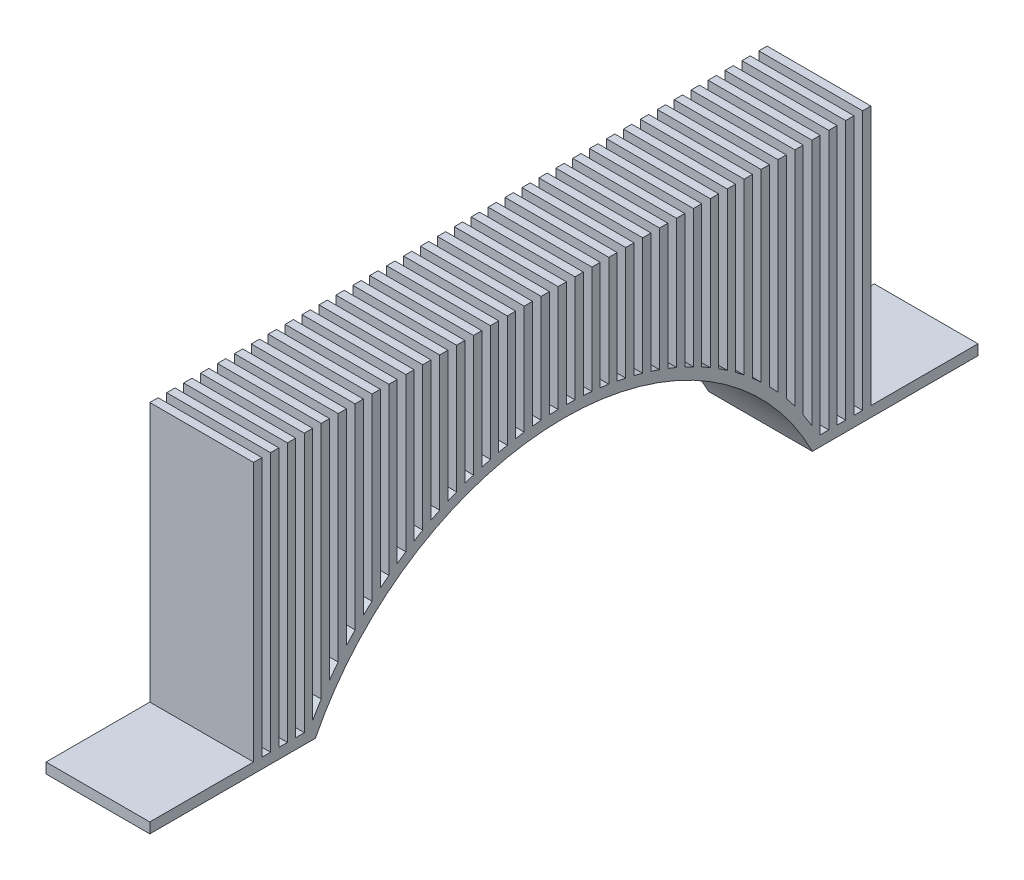
from build123d import *

# Parameters (mm, degrees)
SKETCH1_W           = 0.8
SKETCH1_H           = 25
BOSS_EXTRUDE1_DEPTH = 10


with BuildPart() as part:
    # Sketch1 → Boss-Extrude1 (new body)
    with BuildSketch(Plane(origin=(0, 0, 0), x_dir=(0, 0, -1), z_dir=(1, 0, 0))):
        with Locations((-26.24, 14.5)):
            Rectangle(SKETCH1_W, SKETCH1_H)
        with BuildLine():
            Line((-21.75, 27), (-21.75, 6.264083863))
            ThreePointArc((-21.75, 6.264083863), (-21.355393676, 6.748515695), (-20.95, 7.223956879))
            Line((-20.95, 7.223956879), (-20.95, 27))
            Line((-20.95, 27), (-21.75, 27))
        make_face()
        with BuildLine():
            Line((-20.12, 27), (-20.12, 8.133993328))
            ThreePointArc((-20.12, 8.133993328), (-19.724111766, 8.540799244), (-19.32, 8.939437211))
            Line((-19.32, 8.939437211), (-19.32, 27))
            Line((-19.32, 27), (-20.12, 27))
        make_face()
        with BuildLine():
            ThreePointArc((-18.49, 9.709573695), (-18.093249547, 10.056262597), (-17.69, 10.39537013))
            Line((-17.69, 10.39537013), (-17.69, 27))
            Line((-17.69, 27), (-18.49, 27))
            Line((-18.49, 27), (-18.49, 9.709573695))
        make_face()
        with BuildLine():
            Line((-16.86, 27), (-16.86, 11.053854867))
            ThreePointArc((-16.86, 11.053854867), (-16.462624666, 11.351383643), (-16.06, 11.641769433))
            Line((-16.06, 11.641769433), (-16.06, 27))
            Line((-16.06, 27), (-16.86, 27))
        make_face()
        with BuildLine():
            Line((-15.23, 27), (-15.23, 12.206979598))
            ThreePointArc((-15.23, 12.206979598), (-14.832146447, 12.462707879), (-14.43, 12.711630836))
            Line((-14.43, 12.711630836), (-14.43, 27))
            Line((-14.43, 27), (-15.23, 27))
        make_face()
        with Locations((-29.5, 14.5)):
            Rectangle(SKETCH1_W, SKETCH1_H)
        with BuildLine():
            ThreePointArc((-24.546639281, 2), (-24.38025515, 2.30826182), (-24.21, 2.614402658))
            Line((-24.21, 2.614402658), (-24.21, 27))
            Line((-24.21, 27), (-25.01, 27))
            Line((-25.01, 27), (-25.01, 2))
            Line((-25.01, 2), (-24.546639281, 2))
        make_face()
        with BuildLine():
            Line((-23.38, 27), (-23.38, 3.990465418))
            ThreePointArc((-23.38, 3.990465418), (-22.987525369, 4.583735235), (-22.58, 5.166769099))
            Line((-22.58, 5.166769099), (-22.58, 27))
            Line((-22.58, 27), (-23.38, 27))
        make_face()
        with BuildLine():
            Line((-13.6, 27), (-13.6, 13.196236821))
            ThreePointArc((-13.6, 13.196236821), (-13.201764607, 13.415351239), (-12.8, 13.627925359))
            Line((-12.8, 13.627925359), (-12.8, 27))
            Line((-12.8, 27), (-13.6, 27))
        make_face()
        with BuildLine():
            Line((-11.97, 27), (-11.97, 14.041016321))
            ThreePointArc((-11.97, 14.041016321), (-11.571448918, 14.227293564), (-11.17, 14.40724062))
            Line((-11.17, 14.40724062), (-11.17, 27))
            Line((-11.17, 27), (-11.97, 27))
        make_face()
        with BuildLine():
            Line((-10.34, 27), (-10.34, 14.755511039))
            ThreePointArc((-10.34, 14.755511039), (-9.941180009, 14.911759186), (-9.54, 15.061844056))
            Line((-9.54, 15.061844056), (-9.54, 27))
            Line((-9.54, 27), (-10.34, 27))
        make_face()
        with BuildLine():
            Line((-8.71, 27), (-8.71, 15.350301135))
            ThreePointArc((-8.71, 15.350301135), (-8.31094479, 15.478629755), (-7.91, 15.600926813))
            Line((-7.91, 15.600926813), (-7.91, 27))
            Line((-7.91, 27), (-8.71, 27))
        make_face()
        with BuildLine():
            Line((-7.08, 27), (-7.08, 15.833333127))
            ThreePointArc((-7.08, 15.833333127), (-6.680733977, 15.935325522), (-6.28, 16.031388443))
            Line((-6.28, 16.031388443), (-6.28, 27))
            Line((-6.28, 27), (-7.08, 27))
        make_face()
        with BuildLine():
            Line((-5.45, 27), (-5.45, 16.210548417))
            ThreePointArc((-5.45, 16.210548417), (-5.050540677, 16.287374396), (-4.65, 16.358347269))
            Line((-4.65, 16.358347269), (-4.65, 27))
            Line((-4.65, 27), (-5.45, 27))
        make_face()
        with BuildLine():
            Line((-3.82, 27), (-3.82, 16.486296047))
            ThreePointArc((-3.82, 16.486296047), (-3.420359517, 16.538786504), (-3.02, 16.585477199))
            Line((-3.02, 16.585477199), (-3.02, 27))
            Line((-3.02, 27), (-3.82, 27))
        make_face()
        with BuildLine():
            Line((-2.19, 27), (-2.19, 16.663604962))
            ThreePointArc((-2.19, 16.663604962), (-1.790186091, 16.692300441), (-1.39, 16.715228254))
            Line((-1.39, 16.715228254), (-1.39, 27))
            Line((-1.39, 27), (-2.19, 27))
        make_face()
        with BuildLine():
            ThreePointArc((-0.56, 16.74435914), (-0.160016565, 16.749539469), (0.24, 16.748964009))
            Line((0.24, 16.748964009), (0.24, 27))
            Line((0.24, 27), (-0.56, 27))
            Line((-0.56, 27), (-0.56, 16.74435914))
        make_face()
        with BuildLine():
            ThreePointArc((1.07, 16.729400641), (1.470152617, 16.711099605), (1.87, 16.687034809))
            Line((1.87, 16.687034809), (1.87, 27))
            Line((1.87, 27), (1.07, 27))
            Line((1.07, 27), (1.07, 16.729400641))
        make_face()
        with BuildLine():
            ThreePointArc((2.7, 16.618574231), (3.100324987, 16.576581131), (3.5, 16.528796203))
            Line((3.5, 16.528796203), (3.5, 27))
            Line((3.5, 27), (2.7, 27))
            Line((2.7, 27), (2.7, 16.618574231))
        make_face()
        with BuildLine():
            ThreePointArc((4.33, 16.410719219), (4.730504303, 16.34456751), (5.13, 16.272574915))
            Line((5.13, 16.272574915), (5.13, 27))
            Line((5.13, 27), (4.33, 27))
            Line((4.33, 27), (4.33, 16.410719219))
        make_face()
        with BuildLine():
            ThreePointArc((5.96, 16.103607495), (6.360694834, 16.012549053), (6.76, 15.915578058))
            Line((6.76, 15.915578058), (6.76, 27))
            Line((6.76, 27), (5.96, 27))
            Line((5.96, 27), (5.96, 16.103607495))
        make_face()
        with BuildLine():
            ThreePointArc((7.59, 15.693819847), (7.990901723, 15.576781436), (8.39, 15.453733699))
            Line((8.39, 15.453733699), (8.39, 27))
            Line((8.39, 27), (7.59, 27))
            Line((7.59, 27), (7.59, 15.693819847))
        make_face()
        with BuildLine():
            ThreePointArc((9.22, 15.176543806), (9.621131509, 15.032059514), (10.02, 14.881440377))
            Line((10.02, 14.881440377), (10.02, 27))
            Line((10.02, 27), (9.22, 27))
            Line((9.22, 27), (9.22, 15.176543806))
        make_face()
        with BuildLine():
            ThreePointArc((10.85, 14.545263234), (11.251392917, 14.37137206), (11.65, 14.191186581))
            Line((11.65, 14.191186581), (11.65, 27))
            Line((11.65, 27), (10.85, 27))
            Line((10.85, 27), (10.85, 14.545263234))
        make_face()
        with BuildLine():
            ThreePointArc((12.48, 13.791288211), (12.881698139, 13.585378078), (13.28, 13.372972792))
            Line((13.28, 13.372972792), (13.28, 27))
            Line((13.28, 27), (12.48, 27))
            Line((12.48, 27), (12.48, 13.791288211))
        make_face()
        with BuildLine():
            ThreePointArc((14.11, 12.903035298), (14.51206504, 12.661599868), (14.91, 12.413416205))
            Line((14.91, 12.413416205), (14.91, 27))
            Line((14.91, 27), (14.11, 27))
            Line((14.11, 27), (14.11, 12.903035298))
        make_face()
        with BuildLine():
            ThreePointArc((15.74, 11.864894719), (16.142521191, 11.583139632), (16.54, 11.294314713))
            Line((16.54, 11.294314713), (16.54, 27))
            Line((16.54, 27), (15.74, 27))
            Line((15.74, 27), (15.74, 11.864894719))
        make_face()
        with BuildLine():
            ThreePointArc((17.37, 10.655370303), (17.773111835, 10.326540779), (18.17, 9.990225759))
            Line((18.17, 9.990225759), (18.17, 27))
            Line((18.17, 27), (17.37, 27))
            Line((17.37, 27), (17.37, 10.655370303))
        make_face()
        with BuildLine():
            ThreePointArc((19, 9.24384143), (19.403917134, 8.857988342), (19.8, 8.464097468))
            Line((19.8, 8.464097468), (19.8, 27))
            Line((19.8, 27), (19, 27))
            Line((19, 27), (19, 9.24384143))
        make_face()
        with BuildLine():
            ThreePointArc((20.63, 7.584460014), (21.035094403, 7.125940236), (21.43, 6.658616547))
            Line((21.43, 6.658616547), (21.43, 27))
            Line((21.43, 27), (20.63, 27))
            Line((20.63, 27), (20.63, 7.584460014))
        make_face()
        with BuildLine():
            Line((22.26, 27), (22.26, 5.603299973))
            ThreePointArc((22.26, 5.603299973), (22.6670012, 5.044938851), (23.06, 4.47663518))
            Line((23.06, 4.47663518), (23.06, 27))
            Line((23.06, 27), (22.26, 27))
        make_face()
        with BuildLine():
            Line((23.89, 27), (23.89, 3.166465806))
            ThreePointArc((23.89, 3.166465806), (24.225341418, 2.587185676), (24.546639281, 2))
            Line((24.546639281, 2), (24.69, 2))
            Line((24.69, 2), (24.69, 27))
            Line((24.69, 27), (23.89, 27))
        make_face()
        with Locations((25.92, 14.5)):
            Rectangle(SKETCH1_W, SKETCH1_H)
        with Locations((27.55, 14.5)):
            Rectangle(SKETCH1_W, SKETCH1_H)
        with BuildLine():
            Line((23.938201687, 1), (29.9, 1))
            Line((29.9, 1), (39.9, 1))
            Line((39.9, 1), (39.9, 2))
            Line((39.9, 2), (29.58, 2))
            Line((29.58, 2), (28.78, 2))
            Line((28.78, 2), (27.95, 2))
            Line((27.95, 2), (27.15, 2))
            Line((27.15, 2), (26.32, 2))
            Line((26.32, 2), (25.52, 2))
            Line((25.52, 2), (24.69, 2))
            Line((24.69, 2), (24.546639281, 2))
            Line((24.546639281, 2), (23.89, 2))
            Line((23.89, 2), (23.89, 3.166465806))
            ThreePointArc((23.89, 3.166465806), (23.484138497, 3.827339784), (23.06, 4.47663518))
            Line((23.06, 4.47663518), (23.06, 2.605636199))
            ThreePointArc((23.06, 2.605636199), (23.512810494, 1.810316584), (23.938201687, 1))
        make_face()
        with BuildLine():
            ThreePointArc((24.546639281, 2), (24.225341418, 2.587185676), (23.89, 3.166465806))
            Line((23.89, 3.166465806), (23.89, 2))
            Line((23.89, 2), (24.546639281, 2))
        make_face()
        with BuildLine():
            Line((22.26, 5.603299973), (22.26, 3.874221923))
            ThreePointArc((22.26, 3.874221923), (22.668875743, 3.245526313), (23.06, 2.605636199))
            Line((23.06, 2.605636199), (23.06, 4.47663518))
            ThreePointArc((23.06, 4.47663518), (22.6670012, 5.044938851), (22.26, 5.603299973))
        make_face()
        with BuildLine():
            Line((21.43, 6.658616547), (21.43, 5.043324703))
            ThreePointArc((21.43, 5.043324703), (21.85281962, 4.464324822), (22.26, 3.874221923))
            Line((22.26, 3.874221923), (22.26, 5.603299973))
            ThreePointArc((22.26, 5.603299973), (21.851371771, 6.135969619), (21.43, 6.658616547))
        make_face()
        with BuildLine():
            ThreePointArc((20.63, 6.056814432), (21.036104448, 5.554888125), (21.43, 5.043324703))
            Line((21.43, 5.043324703), (21.43, 6.658616547))
            ThreePointArc((21.43, 6.658616547), (21.035094403, 7.125940236), (20.63, 7.584460014))
            Line((20.63, 7.584460014), (20.63, 6.056814432))
        make_face()
        with BuildLine():
            ThreePointArc((19.8, 7.011007724), (20.220629224, 6.538807628), (20.63, 6.056814432))
            Line((20.63, 6.056814432), (20.63, 7.584460014))
            ThreePointArc((20.63, 7.584460014), (20.219784013, 8.028792794), (19.8, 8.464097468))
            Line((19.8, 8.464097468), (19.8, 7.011007724))
        make_face()
        with BuildLine():
            ThreePointArc((19, 7.850793634), (19.404543543, 7.435228965), (19.8, 7.011007724))
            Line((19.8, 7.011007724), (19.8, 8.464097468))
            ThreePointArc((19.8, 8.464097468), (19.403917134, 8.857988342), (19, 9.24384143))
            Line((19, 9.24384143), (19, 7.850793634))
        make_face()
        with BuildLine():
            Line((18.17, 9.990225759), (18.17, 8.650027919))
            ThreePointArc((18.17, 8.650027919), (18.589295814, 8.254871953), (19, 7.850793634))
            Line((19, 7.850793634), (19, 9.24384143))
            ThreePointArc((19, 9.24384143), (18.588746526, 9.621199835), (18.17, 9.990225759))
        make_face()
        with BuildLine():
            ThreePointArc((17.37, 9.358897569), (17.773534371, 9.008451484), (18.17, 8.650027919))
            Line((18.17, 8.650027919), (18.17, 9.990225759))
            ThreePointArc((18.17, 9.990225759), (17.773111835, 10.326540779), (17.37, 10.655370303))
            Line((17.37, 10.655370303), (17.37, 9.358897569))
        make_face()
        with BuildLine():
            ThreePointArc((16.54, 10.037161971), (16.958391305, 9.702179749), (17.37, 9.358897569))
            Line((17.37, 9.358897569), (17.37, 10.655370303))
            ThreePointArc((17.37, 10.655370303), (16.958009538, 10.978751951), (16.54, 11.294314713))
            Line((16.54, 11.294314713), (16.54, 10.037161971))
        make_face()
        with BuildLine():
            Line((-39.9, 1), (-29.9, 1))
            Line((-29.9, 1), (-23.938201687, 1))
            ThreePointArc((-23.938201687, 1), (-23.664927423, 1.528203769), (-23.38, 2.050213739))
            Line((-23.38, 2.050213739), (-23.38, 3.990465418))
            ThreePointArc((-23.38, 3.990465418), (-23.80494512, 3.308432638), (-24.21, 2.614402658))
            Line((-24.21, 2.614402658), (-24.21, 2))
            Line((-24.21, 2), (-24.546639281, 2))
            Line((-24.546639281, 2), (-25.01, 2))
            Line((-25.01, 2), (-25.84, 2))
            Line((-25.84, 2), (-26.64, 2))
            Line((-26.64, 2), (-27.47, 2))
            Line((-27.47, 2), (-28.27, 2))
            Line((-28.27, 2), (-29.1, 2))
            Line((-29.1, 2), (-29.9, 2))
            Line((-29.9, 2), (-39.9, 2))
            Line((-39.9, 2), (-39.9, 1))
        make_face()
        with BuildLine():
            Line((-23.38, 3.990465418), (-23.38, 2.050213739))
            ThreePointArc((-23.38, 2.050213739), (-22.989696517, 2.723665236), (-22.58, 3.385497913))
            Line((-22.58, 3.385497913), (-22.58, 5.166769099))
            ThreePointArc((-22.58, 5.166769099), (-22.987525369, 4.583735235), (-23.38, 3.990465418))
        make_face()
        with BuildLine():
            Line((-24.21, 2), (-24.21, 2.614402658))
            ThreePointArc((-24.21, 2.614402658), (-24.38025515, 2.30826182), (-24.546639281, 2))
            Line((-24.546639281, 2), (-24.21, 2))
        make_face()
        with BuildLine():
            ThreePointArc((-22.58, 3.385497913), (-22.173428724, 4.002543261), (-21.75, 4.608144845))
            Line((-21.75, 4.608144845), (-21.75, 6.264083863))
            ThreePointArc((-21.75, 6.264083863), (-22.171789507, 5.720562008), (-22.58, 5.166769099))
            Line((-22.58, 5.166769099), (-22.58, 3.385497913))
        make_face()
        with BuildLine():
            Line((-21.75, 6.264083863), (-21.75, 4.608144845))
            ThreePointArc((-21.75, 4.608144845), (-21.356518609, 5.140710698), (-20.95, 5.663392833))
            Line((-20.95, 5.663392833), (-20.95, 7.223956879))
            ThreePointArc((-20.95, 7.223956879), (-21.355393676, 6.748515695), (-21.75, 6.264083863))
        make_face()
        with BuildLine():
            Line((-20.95, 7.223956879), (-20.95, 5.663392833))
            ThreePointArc((-20.95, 5.663392833), (-20.540970437, 6.163614772), (-20.12, 6.653830094))
            Line((-20.12, 6.653830094), (-20.12, 8.133993328))
            ThreePointArc((-20.12, 8.133993328), (-20.540040569, 7.683572361), (-20.95, 7.223956879))
        make_face()
        with BuildLine():
            Line((-20.12, 8.133993328), (-20.12, 6.653830094))
            ThreePointArc((-20.12, 6.653830094), (-19.724794372, 7.093111282), (-19.32, 7.523572623))
            Line((-19.32, 7.523572623), (-19.32, 8.939437211))
            ThreePointArc((-19.32, 8.939437211), (-19.724111766, 8.540799244), (-20.12, 8.133993328))
        make_face()
        with BuildLine():
            ThreePointArc((-19.32, 7.523572623), (-18.909515316, 7.941319873), (-18.49, 8.349997423))
            Line((-18.49, 8.349997423), (-18.49, 9.709573695))
            ThreePointArc((-18.49, 9.709573695), (-18.908921242, 9.328731498), (-19.32, 8.939437211))
            Line((-19.32, 8.939437211), (-19.32, 7.523572623))
        make_face()
        with BuildLine():
            ThreePointArc((-18.49, 8.349997423), (-18.093703762, 8.720126054), (-17.69, 9.082160838))
            Line((-17.69, 9.082160838), (-17.69, 10.39537013))
            ThreePointArc((-17.69, 10.39537013), (-18.093249547, 10.056262597), (-18.49, 9.709573695))
            Line((-18.49, 9.709573695), (-18.49, 8.349997423))
        make_face()
        with BuildLine():
            ThreePointArc((-17.69, 9.082160838), (-17.278545581, 9.43638237), (-16.86, 9.782196236))
            Line((-16.86, 9.782196236), (-16.86, 11.053854867))
            ThreePointArc((-16.86, 11.053854867), (-17.278137213, 10.72856686), (-17.69, 10.39537013))
            Line((-17.69, 10.39537013), (-17.69, 9.082160838))
        make_face()
        with BuildLine():
            Line((-16.86, 11.053854867), (-16.86, 9.782196236))
            ThreePointArc((-16.86, 9.782196236), (-16.462945259, 10.097374149), (-16.06, 10.404985435))
            Line((-16.06, 10.404985435), (-16.06, 11.641769433))
            ThreePointArc((-16.06, 11.641769433), (-16.462624666, 11.351383643), (-16.86, 11.053854867))
        make_face()
        with BuildLine():
            Line((-16.06, 11.641769433), (-16.06, 10.404985435))
            ThreePointArc((-16.06, 10.404985435), (-15.647846727, 10.707410066), (-15.23, 11.001918284))
            Line((-15.23, 11.001918284), (-15.23, 12.206979598))
            ThreePointArc((-15.23, 12.206979598), (-15.647552225, 11.928122407), (-16.06, 11.641769433))
        make_face()
        with BuildLine():
            Line((-15.23, 12.206979598), (-15.23, 11.001918284))
            ThreePointArc((-15.23, 11.001918284), (-14.832381753, 11.2713004), (-14.43, 11.533513898))
            Line((-14.43, 11.533513898), (-14.43, 12.711630836))
            ThreePointArc((-14.43, 12.711630836), (-14.832146447, 12.462707879), (-15.23, 12.206979598))
        make_face()
        with BuildLine():
            Line((-14.43, 12.711630836), (-14.43, 11.533513898))
            ThreePointArc((-14.43, 11.533513898), (-14.017313664, 11.791955206), (-13.6, 12.042856038))
            Line((-13.6, 12.042856038), (-13.6, 13.196236821))
            ThreePointArc((-13.6, 13.196236821), (-14.017094411, 12.957520994), (-14.43, 12.711630836))
        make_face()
        with BuildLine():
            Line((-13.6, 13.196236821), (-13.6, 12.042856038))
            ThreePointArc((-13.6, 12.042856038), (-13.201941788, 12.272708527), (-12.8, 12.495700244))
            Line((-12.8, 12.495700244), (-12.8, 13.627925359))
            ThreePointArc((-12.8, 13.627925359), (-13.201764607, 13.415351239), (-13.6, 13.196236821))
        make_face()
        with BuildLine():
            Line((-12.8, 13.627925359), (-12.8, 12.495700244))
            ThreePointArc((-12.8, 12.495700244), (-12.3868887, 12.715626193), (-11.97, 12.928304777))
            Line((-11.97, 12.928304777), (-11.97, 14.041016321))
            ThreePointArc((-11.97, 14.041016321), (-12.386722167, 13.83793109), (-12.8, 13.627925359))
        make_face()
        with BuildLine():
            Line((-11.17, 14.40724062), (-11.17, 13.311262283))
            ThreePointArc((-11.17, 13.311262283), (-10.756537397, 13.496627125), (-10.34, 13.674975227))
            Line((-10.34, 13.674975227), (-10.34, 14.755511039))
            ThreePointArc((-10.34, 14.755511039), (-10.756409627, 14.584735262), (-11.17, 14.40724062))
        make_face()
        with BuildLine():
            Line((-10.34, 14.755511039), (-10.34, 13.674975227))
            ThreePointArc((-10.34, 13.674975227), (-9.941284049, 13.837966398), (-9.54, 13.994528345))
            Line((-9.54, 13.994528345), (-9.54, 15.061844056))
            ThreePointArc((-9.54, 15.061844056), (-9.941180009, 14.911759186), (-10.34, 14.755511039))
        make_face()
        with BuildLine():
            Line((-9.54, 15.061844056), (-9.54, 13.994528345))
            ThreePointArc((-9.54, 13.994528345), (-9.126237789, 14.148249618), (-8.71, 14.295135628))
            Line((-8.71, 14.295135628), (-8.71, 15.350301135))
            ThreePointArc((-8.71, 15.350301135), (-9.126139757, 15.209352108), (-9.54, 15.061844056))
        make_face()
        with BuildLine():
            Line((-8.71, 15.350301135), (-8.71, 14.295135628))
            ThreePointArc((-8.71, 14.295135628), (-8.311024271, 14.428753415), (-7.91, 14.556091072))
            Line((-7.91, 14.556091072), (-7.91, 15.600926813))
            ThreePointArc((-7.91, 15.600926813), (-8.31094479, 15.478629755), (-8.71, 15.350301135))
        make_face()
        with BuildLine():
            Line((-7.91, 15.600926813), (-7.91, 14.556091072))
            ThreePointArc((-7.91, 14.556091072), (-7.49597506, 14.680339249), (-7.08, 14.797893531))
            Line((-7.08, 14.797893531), (-7.08, 15.833333127))
            ThreePointArc((-7.08, 15.833333127), (-7.495900758, 15.720346875), (-7.91, 15.600926813))
        make_face()
        with BuildLine():
            Line((-7.08, 15.833333127), (-7.08, 14.797893531))
            ThreePointArc((-7.08, 14.797893531), (-6.680793482, 14.903939941), (-6.28, 15.003821217))
            Line((-6.28, 15.003821217), (-6.28, 16.031388443))
            ThreePointArc((-6.28, 16.031388443), (-6.680733977, 15.935325522), (-7.08, 15.833333127))
        make_face()
        with BuildLine():
            Line((-6.28, 16.031388443), (-6.28, 15.003821217))
            ThreePointArc((-6.28, 15.003821217), (-5.865738697, 15.100202859), (-5.45, 15.189998095))
            Line((-5.45, 15.189998095), (-5.45, 16.210548417))
            ThreePointArc((-5.45, 16.210548417), (-5.865684067, 16.124137529), (-6.28, 16.031388443))
        make_face()
        with BuildLine():
            Line((-5.45, 16.210548417), (-5.45, 15.189998095))
            ThreePointArc((-5.45, 15.189998095), (-5.050583299, 15.26979499), (-4.65, 15.34351246))
            Line((-4.65, 15.34351246), (-4.65, 16.358347269))
            ThreePointArc((-4.65, 16.358347269), (-5.050540677, 16.287374396), (-5.45, 16.210548417))
        make_face()
        with BuildLine():
            Line((-4.65, 16.358347269), (-4.65, 15.34351246))
            ThreePointArc((-4.65, 15.34351246), (-4.235520853, 15.413188831), (-3.82, 15.476356704))
            Line((-3.82, 15.476356704), (-3.82, 16.486296047))
            ThreePointArc((-3.82, 16.486296047), (-4.235483175, 16.425455998), (-4.65, 16.358347269))
        make_face()
        with BuildLine():
            Line((-3.82, 16.486296047), (-3.82, 15.476356704))
            ThreePointArc((-3.82, 15.476356704), (-3.420387304, 15.530838036), (-3.02, 15.579299653))
            Line((-3.02, 15.579299653), (-3.02, 16.585477199))
            ThreePointArc((-3.02, 16.585477199), (-3.420359517, 16.538786504), (-3.82, 16.486296047))
        make_face()
        with BuildLine():
            Line((-3.02, 16.585477199), (-3.02, 15.579299653))
            ThreePointArc((-3.02, 15.579299653), (-2.60531536, 15.623063789), (-2.19, 15.660370645))
            Line((-2.19, 15.660370645), (-2.19, 16.663604962))
            ThreePointArc((-2.19, 16.663604962), (-2.605292879, 16.62765252), (-3.02, 16.585477199))
        make_face()
        with BuildLine():
            Line((-2.19, 16.663604962), (-2.19, 15.660370645))
            ThreePointArc((-2.19, 15.660370645), (-1.790200303, 15.690141789), (-1.39, 15.713929084))
            Line((-1.39, 15.713929084), (-1.39, 16.715228254))
            ThreePointArc((-1.39, 16.715228254), (-1.790186091, 16.692300441), (-2.19, 16.663604962))
        make_face()
        with BuildLine():
            Line((-11.97, 14.041016321), (-11.97, 12.928304777))
            ThreePointArc((-11.97, 12.928304777), (-11.571584339, 13.123093221), (-11.17, 13.311262283))
            Line((-11.17, 13.311262283), (-11.17, 14.40724062))
            ThreePointArc((-11.17, 14.40724062), (-11.571448918, 14.227293564), (-11.97, 14.041016321))
        make_face()
        with BuildLine():
            Line((-1.39, 16.715228254), (-1.39, 15.713929084))
            ThreePointArc((-1.39, 15.713929084), (-0.975117072, 15.732254324), (-0.56, 15.744148615))
            Line((-0.56, 15.744148615), (-0.56, 16.74435914))
            ThreePointArc((-0.56, 16.74435914), (-0.97510879, 16.732893349), (-1.39, 16.715228254))
        make_face()
        with BuildLine():
            ThreePointArc((-0.56, 15.744148615), (-0.160017825, 15.749522277), (0.24, 15.748925352))
            Line((0.24, 15.748925352), (0.24, 16.748964009))
            ThreePointArc((0.24, 16.748964009), (-0.160016565, 16.749539469), (-0.56, 16.74435914))
            Line((-0.56, 16.74435914), (-0.56, 15.744148615))
        make_face()
        with BuildLine():
            ThreePointArc((0.24, 15.748925352), (0.655078592, 15.741992685), (1.07, 15.728631406))
            Line((1.07, 15.728631406), (1.07, 16.729400641))
            ThreePointArc((1.07, 16.729400641), (0.655073035, 16.74228093), (0.24, 16.748964009))
            Line((0.24, 16.748964009), (0.24, 15.748925352))
        make_face()
        with BuildLine():
            ThreePointArc((1.07, 15.728631406), (1.470164255, 15.709645309), (1.87, 15.684679725))
            Line((1.87, 15.684679725), (1.87, 16.687034809))
            ThreePointArc((1.87, 16.687034809), (1.470152617, 16.711099605), (1.07, 16.729400641))
            Line((1.07, 16.729400641), (1.07, 15.728631406))
        make_face()
        with BuildLine():
            ThreePointArc((1.87, 15.684679725), (2.285276014, 15.652387787), (2.7, 15.613645662))
            Line((2.7, 15.613645662), (2.7, 16.618574231))
            ThreePointArc((2.7, 16.618574231), (2.285256378, 16.655912786), (1.87, 16.687034809))
            Line((1.87, 16.687034809), (1.87, 15.684679725))
        make_face()
        with BuildLine():
            ThreePointArc((2.7, 15.613645662), (3.100350031, 15.570064419), (3.5, 15.520472333))
            Line((3.5, 15.520472333), (3.5, 16.528796203))
            ThreePointArc((3.5, 16.528796203), (3.100324987, 16.576581131), (2.7, 16.618574231))
            Line((2.7, 16.618574231), (2.7, 15.613645662))
        make_face()
        with BuildLine():
            ThreePointArc((3.5, 15.520472333), (3.91547971, 15.462431398), (4.33, 15.397894056))
            Line((4.33, 15.397894056), (4.33, 16.410719219))
            ThreePointArc((4.33, 16.410719219), (3.915445127, 16.472886648), (3.5, 16.528796203))
            Line((3.5, 16.528796203), (3.5, 15.520472333))
        make_face()
        with BuildLine():
            ThreePointArc((4.33, 15.397894056), (4.73054388, 15.329195488), (5.13, 15.254431186))
            Line((5.13, 15.254431186), (5.13, 16.272574915))
            ThreePointArc((5.13, 16.272574915), (4.730504303, 16.34456751), (4.33, 16.410719219))
            Line((4.33, 16.410719219), (4.33, 15.397894056))
        make_face()
        with BuildLine():
            ThreePointArc((5.13, 15.254431186), (5.545694682, 15.169940322), (5.96, 15.078880573))
            Line((5.96, 15.078880573), (5.96, 16.103607495))
            ThreePointArc((5.96, 16.103607495), (5.54564356, 16.191252495), (5.13, 16.272574915))
            Line((5.13, 16.272574915), (5.13, 15.254431186))
        make_face()
        with BuildLine():
            ThreePointArc((5.96, 15.078880573), (6.360750818, 14.984224571), (6.76, 14.883422451))
            Line((6.76, 14.883422451), (6.76, 15.915578058))
            ThreePointArc((6.76, 15.915578058), (6.360694834, 16.012549053), (5.96, 16.103607495))
            Line((5.96, 16.103607495), (5.96, 15.078880573))
        make_face()
        with BuildLine():
            ThreePointArc((6.76, 14.883422451), (7.175926855, 14.771426641), (7.59, 14.652760552))
            Line((7.59, 14.652760552), (7.59, 15.693819847))
            ThreePointArc((7.59, 15.693819847), (7.175856686, 15.807905369), (6.76, 15.915578058))
            Line((6.76, 15.915578058), (6.76, 14.883422451))
        make_face()
        with BuildLine():
            ThreePointArc((7.59, 14.652760552), (7.990976975, 14.530936007), (8.39, 14.402856421))
            Line((8.39, 14.402856421), (8.39, 15.453733699))
            ThreePointArc((8.39, 15.453733699), (7.990901723, 15.576781436), (7.59, 15.693819847))
            Line((7.59, 15.693819847), (7.59, 14.652760552))
        make_face()
        with BuildLine():
            ThreePointArc((8.39, 14.402856421), (8.80618368, 14.261877232), (9.22, 14.114093467))
            Line((9.22, 14.114093467), (9.22, 15.176543806))
            ThreePointArc((9.22, 15.176543806), (8.806090708, 15.3184047), (8.39, 15.453733699))
            Line((8.39, 15.453733699), (8.39, 14.402856421))
        make_face()
        with BuildLine():
            ThreePointArc((9.22, 14.114093467), (9.621230274, 13.963434951), (10.02, 13.806379463))
            Line((10.02, 13.806379463), (10.02, 14.881440377))
            ThreePointArc((10.02, 14.881440377), (9.621131509, 15.032059514), (9.22, 15.176543806))
            Line((9.22, 15.176543806), (9.22, 14.114093467))
        make_face()
        with BuildLine():
            ThreePointArc((10.02, 13.806379463), (10.436475045, 13.634407804), (10.85, 13.455458576))
            Line((10.85, 13.455458576), (10.85, 14.545263234))
            ThreePointArc((10.85, 14.545263234), (10.43635371, 14.71669403), (10.02, 14.881440377))
            Line((10.02, 14.881440377), (10.02, 13.806379463))
        make_face()
        with BuildLine():
            ThreePointArc((10.85, 13.455458576), (11.251521496, 13.273718138), (11.65, 13.085399313))
            Line((11.65, 13.085399313), (11.65, 14.191186581))
            ThreePointArc((11.65, 14.191186581), (11.251392917, 14.37137206), (10.85, 14.545263234))
            Line((10.85, 14.545263234), (10.85, 13.455458576))
        make_face()
        with BuildLine():
            ThreePointArc((11.65, 13.085399313), (12.066814746, 12.879730084), (12.48, 12.666863199))
            Line((12.48, 12.666863199), (12.48, 13.791288211))
            ThreePointArc((12.48, 13.791288211), (12.066656732, 13.994675988), (11.65, 14.191186581))
            Line((11.65, 14.191186581), (11.65, 13.085399313))
        make_face()
        with BuildLine():
            ThreePointArc((12.48, 12.666863199), (12.881866067, 12.451011183), (13.28, 12.228350457))
            Line((13.28, 12.228350457), (13.28, 13.372972792))
            ThreePointArc((13.28, 13.372972792), (12.881698139, 13.585378078), (12.48, 13.791288211))
            Line((12.48, 13.791288211), (12.48, 12.666863199))
        make_face()
        with BuildLine():
            ThreePointArc((13.28, 12.228350457), (13.69722303, 11.985322469), (14.11, 11.734817313))
            Line((14.11, 11.734817313), (14.11, 12.903035298))
            ThreePointArc((14.11, 12.903035298), (13.697015562, 13.141563916), (13.28, 13.372972792))
            Line((13.28, 13.372972792), (13.28, 12.228350457))
        make_face()
        with BuildLine():
            ThreePointArc((14.11, 11.734817313), (14.51228723, 11.480723898), (14.91, 11.219528509))
            Line((14.91, 11.219528509), (14.91, 12.413416205))
            ThreePointArc((14.91, 12.413416205), (14.51206504, 12.661599868), (14.11, 12.903035298))
            Line((14.11, 12.903035298), (14.11, 11.734817313))
        make_face()
        with BuildLine():
            ThreePointArc((14.91, 11.219528509), (15.327731275, 10.934100026), (15.74, 10.640836775))
            Line((15.74, 10.640836775), (15.74, 11.864894719))
            ThreePointArc((15.74, 11.864894719), (15.327453929, 12.142868646), (14.91, 12.413416205))
            Line((14.91, 12.413416205), (14.91, 11.219528509))
        make_face()
        with BuildLine():
            ThreePointArc((15.74, 10.640836775), (16.142822114, 10.342739287), (16.54, 10.037161971))
            Line((16.54, 10.037161971), (16.54, 11.294314713))
            ThreePointArc((16.54, 11.294314713), (16.142521191, 11.583139632), (15.74, 11.864894719))
            Line((15.74, 11.864894719), (15.74, 10.640836775))
        make_face()
        with Locations((29.18, 14.5)):
            Rectangle(SKETCH1_W, SKETCH1_H)
        with Locations((-27.87, 14.5)):
            Rectangle(SKETCH1_W, SKETCH1_H)
    extrude(amount=BOSS_EXTRUDE1_DEPTH)


solid = part.part
